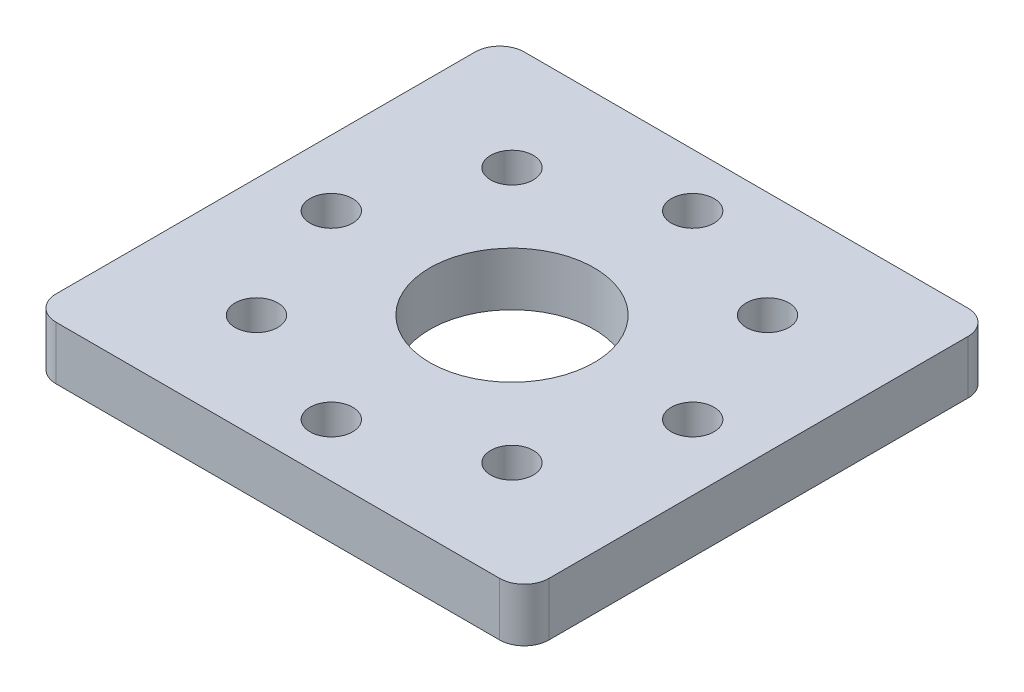
from build123d import *

# Parameters (mm, degrees)
SKETCH1_W                = 30
SKETCH1_H                = 28.5
BOSS_EXTRUDE1_DEPTH      = 0.1
BOSS_EXTRUDE1_DEPTH_BACK = 3.15
SKETCH2_R                = 5
SKETCH2_R_2              = 1.3
CUT_EXTRUDE1_DEPTH       = 4.25
FILLET1_R                = 1.5


with BuildPart() as part:
    # Sketch1 → Boss-Extrude1 (new body, two sides)
    with BuildSketch(Plane(origin=(0, 0, 0), x_dir=(1, 0, 0), z_dir=(0, 1, 0))) as boss_extrude1_sk:
        Rectangle(SKETCH1_W, SKETCH1_H)
    extrude(amount=BOSS_EXTRUDE1_DEPTH)
    extrude(boss_extrude1_sk.sketch, amount=-BOSS_EXTRUDE1_DEPTH_BACK)

    # Sketch2 → Cut-Extrude1 (cut, through all)
    with BuildSketch(Plane(origin=(0, 0.1, 0), x_dir=(1, 0, 0), z_dir=(0, 1, 0))):
        Circle(SKETCH2_R)
        with Locations((0, 11)):
            Circle(SKETCH2_R_2)
        with Locations((7.778174593, 7.778174593)):
            Circle(SKETCH2_R_2)
        with Locations((11, 0)):
            Circle(SKETCH2_R_2)
        with Locations((7.778174593, -7.778174593)):
            Circle(SKETCH2_R_2)
        with Locations((0, -11)):
            Circle(SKETCH2_R_2)
        with Locations((-7.778174593, -7.778174593)):
            Circle(SKETCH2_R_2)
        with Locations((-11, 0)):
            Circle(SKETCH2_R_2)
        with Locations((-7.778174593, 7.778174593)):
            Circle(SKETCH2_R_2)
    extrude(amount=-CUT_EXTRUDE1_DEPTH, mode=Mode.SUBTRACT)

    # Fillet1
    fillet1_edges = [part.edges().sort_by_distance(p)[0] for p in [
        (-15, -1.525, -14.25),
        (15, -1.525, -14.25),
        (15, -1.525, 14.25),
        (-15, -1.525, 14.25),
    ]]
    fillet(fillet1_edges, radius=FILLET1_R)


solid = part.part
